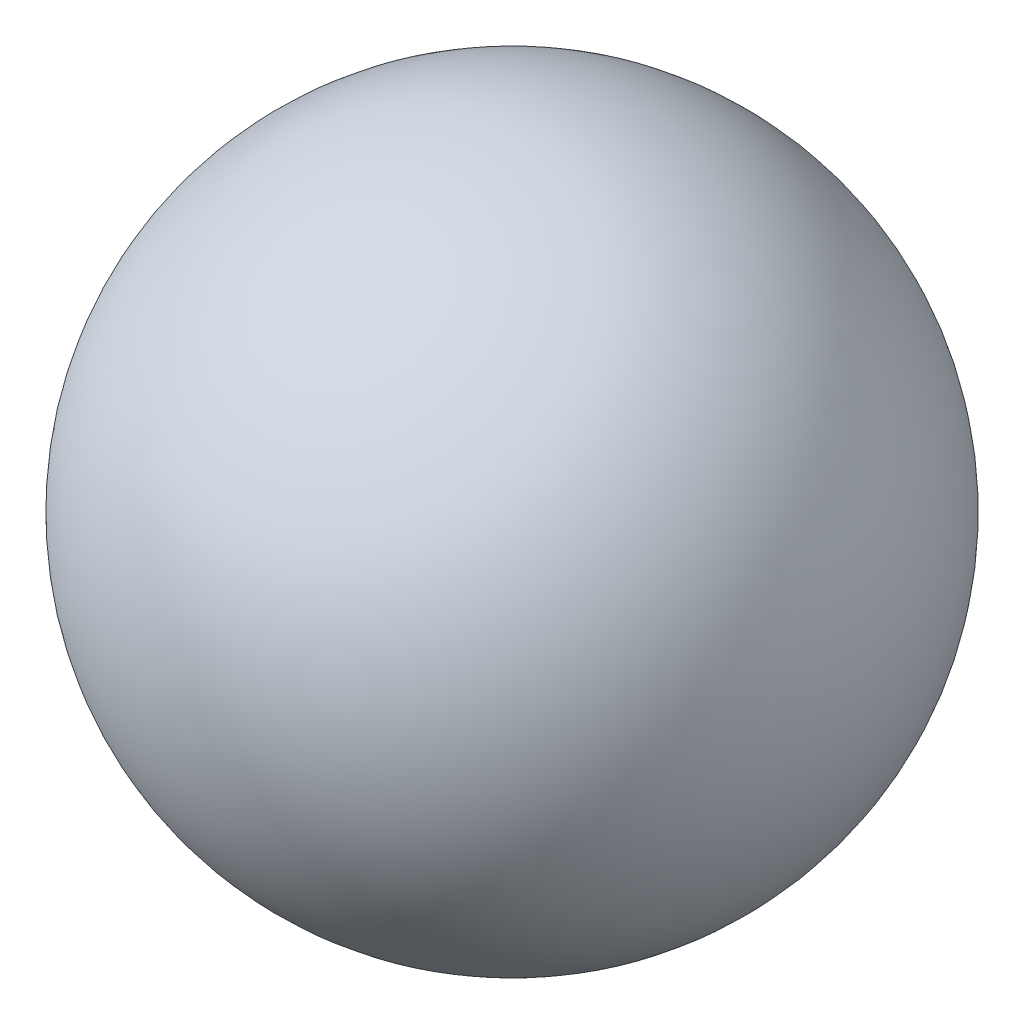
from build123d import *


with BuildPart() as part:
    # Sketch1 one side → Revolve1 (revolve)
    with BuildSketch(Plane.XY):
        with BuildLine():
            ThreePointArc((0, 0), (116.743329574, 48.356670426), (165.1, 165.1))
            ThreePointArc((165.1, 165.1), (116.743329574, 281.843329574), (0, 330.2))
            Line((0, 330.2), (0, 0))
        make_face()
    revolve(axis=Axis((0, 330.2, 0), (0, -1, 0)))


solid = part.part
